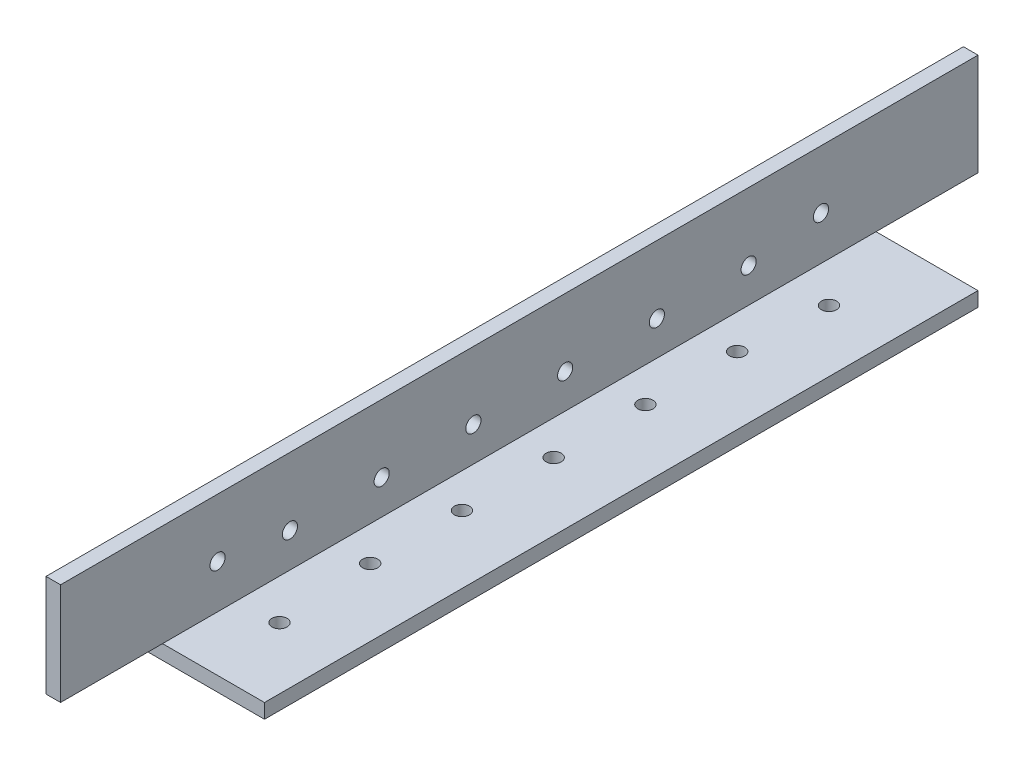
from build123d import *

# Parameters (mm, degrees)
BOSS_EXTRUDE1_DEPTH = 1219.2
FILLET1_R           = 0.4064
SKETCH4_W           = 2238.4
SKETCH4_H           = 103.278519729
CUT_EXTRUDE1_DEPTH  = 60
SKETCH5_W           = 25.4
SKETCH5_H           = 22.23
CUT_EXTRUDE2_DEPTH  = 3.175
SKETCH6_W           = 25.4
SKETCH6_H           = 22.23
CUT_EXTRUDE3_DEPTH  = 3.175
SKETCH7_W           = 1.26890891
SKETCH7_H           = 1.024965533
CUT_EXTRUDE4_DEPTH  = 220
SKETCH9_R           = 1.65
CUT_EXTRUDE5_DEPTH  = 20
SKETCH10_R          = 1.65
CUT_EXTRUDE6_DEPTH  = 20
SKETCH11_R          = 1.65
CUT_EXTRUDE7_DEPTH  = 70
SKETCH12_R          = 1.65
CUT_EXTRUDE8_DEPTH  = 70


with BuildPart() as part:
    # Sketch3 → Boss-Extrude1 (new, symmetric)
    with BuildSketch(Plane.XY):
        Polygon((3.175, 25.4), (0, 25.4), (0, 0), (25.4, 0), (25.4, 3.175), (3.175, 3.175), align=None)
    extrude(amount=BOSS_EXTRUDE1_DEPTH, both=True)

    # Fillet1
    fillet1_edges = [part.edges().sort_by_distance(p)[0] for p in [
        (3.175, 3.175, 0),
    ]]
    fillet(fillet1_edges, radius=FILLET1_R)

    # Sketch4 → Cut-Extrude1 (cut)
    with BuildSketch(Plane.ZY):
        with Locations((-100, -26.239259864)):
            Rectangle(SKETCH4_W, SKETCH4_H)
    extrude(amount=-CUT_EXTRUDE1_DEPTH, mode=Mode.SUBTRACT)

    # Sketch5 → Cut-Extrude2 (cut)
    with BuildSketch(Plane.XZ):
        with Locations((12.7, 1030.315)):
            Rectangle(SKETCH5_W, SKETCH5_H)
    extrude(amount=-CUT_EXTRUDE2_DEPTH, mode=Mode.SUBTRACT)

    # Sketch6 → Cut-Extrude3 (cut)
    with BuildSketch(Plane.XZ):
        with Locations((12.7, 1208.085)):
            Rectangle(SKETCH6_W, SKETCH6_H)
    extrude(amount=-CUT_EXTRUDE3_DEPTH, mode=Mode.SUBTRACT)

    # Sketch7 → Cut-Extrude4 (cut)
    with BuildSketch(Plane(origin=(0, 0, 1019.2), x_dir=(-1, 0, 0), z_dir=(0, 0, -1))):
        with Locations((-3.809454455, 3.687482767)):
            Rectangle(SKETCH7_W, SKETCH7_H)
    extrude(amount=-CUT_EXTRUDE4_DEPTH, mode=Mode.SUBTRACT)

    # Sketch9 → Cut-Extrude5 (cut)
    with BuildSketch(Plane(origin=(3.175, 0, 0), x_dir=(0, 0, -1), z_dir=(1, 0, 0))):
        with Locations(Location((-1169.2, 10.675, 0), (0, 0, 90))):
            Circle(SKETCH9_R)
        with Locations(Location((-1149.2, 10.675, 0), (0, 0, 90))):
            Circle(SKETCH9_R)
        with Locations(Location((-1129.2, 10.675, 0), (0, 0, 90))):
            Circle(SKETCH9_R)
        with Locations(Location((-1109.2, 10.675, 0), (0, 0, 90))):
            Circle(SKETCH9_R)
        with Locations(Location((-1089.2, 10.675, 0), (0, 0, 90))):
            Circle(SKETCH9_R)
        with Locations(Location((-1069.2, 10.675, 0), (0, 0, 90))):
            Circle(SKETCH9_R)
    extrude(amount=-CUT_EXTRUDE5_DEPTH, mode=Mode.SUBTRACT)

    # Sketch10 → Cut-Extrude6 (cut)
    with BuildSketch(Plane(origin=(0, 3.175, 0), x_dir=(1, 0, 0), z_dir=(0, 1, 0))):
        with Locations(Location((10.675, -1079.2, 0), (0, 0, 180))):
            Circle(SKETCH10_R)
        with Locations(Location((10.675, -1099.2, 0), (0, 0, 180))):
            Circle(SKETCH10_R)
        with Locations(Location((10.675, -1119.2, 0), (0, 0, 180))):
            Circle(SKETCH10_R)
        with Locations(Location((10.675, -1139.2, 0), (0, 0, 180))):
            Circle(SKETCH10_R)
        with Locations(Location((10.675, -1159.2, 0), (0, 0, 180))):
            Circle(SKETCH10_R)
    extrude(amount=-CUT_EXTRUDE6_DEPTH, mode=Mode.SUBTRACT)

    # Sketch11 → Cut-Extrude7 (cut)
    with BuildSketch(Plane(origin=(3.175, 0, 0), x_dir=(0, 0, -1), z_dir=(1, 0, 0))):
        with Locations(Location((-1053.425704333, 12.7, 0), (0, 0, 90))):
            Circle(SKETCH11_R)
        with Locations(Location((-1184.979295667, 12.7, 0), (0, 0, 90))):
            Circle(SKETCH11_R)
    extrude(amount=-CUT_EXTRUDE7_DEPTH, mode=Mode.SUBTRACT)

    # Sketch12 → Cut-Extrude8 (cut)
    with BuildSketch(Plane(origin=(0, 3.175, 0), x_dir=(1, 0, 0), z_dir=(0, 1, 0))):
        with Locations(Location((11.9634, -1180.260622857, 0), (0, 0, 180))):
            Circle(SKETCH12_R)
        with Locations(Location((11.9634, -1060.48, 0), (0, 0, 180))):
            Circle(SKETCH12_R)
    extrude(amount=-CUT_EXTRUDE8_DEPTH, mode=Mode.SUBTRACT)


solid = part.part
